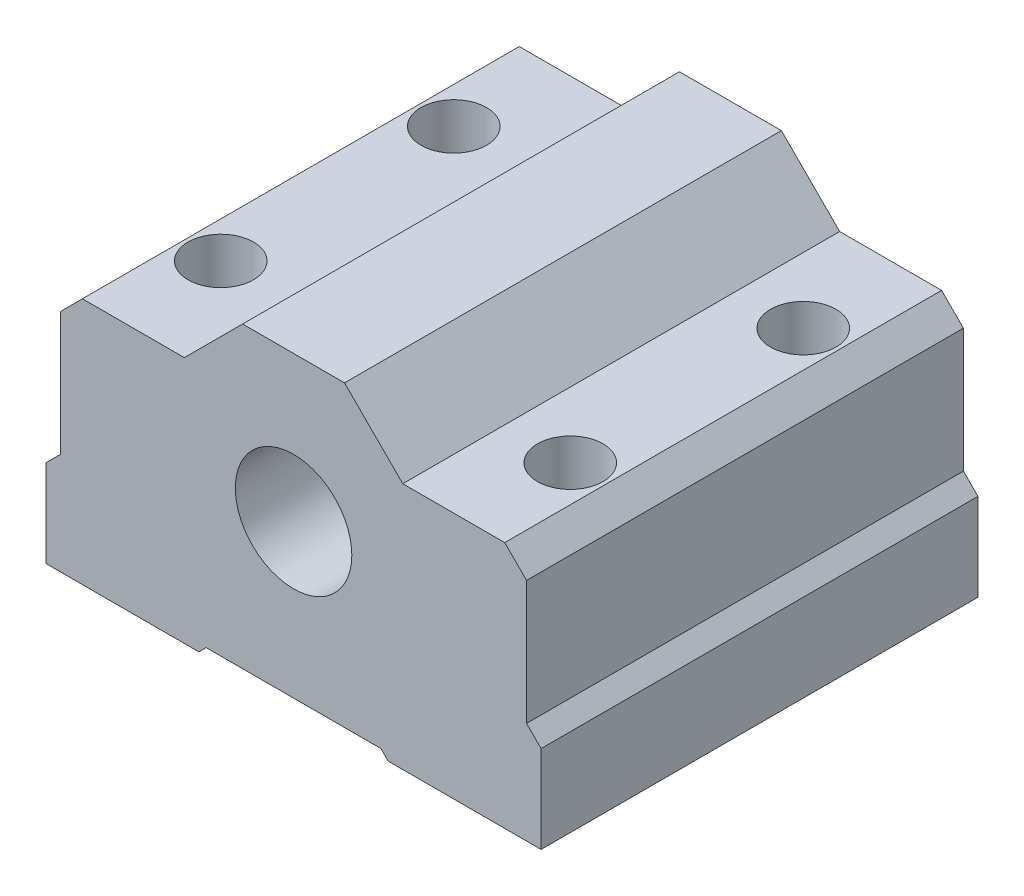
from build123d import *

# Parameters (mm, degrees)
BOSS_EXTRU_1_DEPTH      = 15
BOSS_EXTRU_1_DEPTH_BACK = 15
ESQUISSE1_R             = 4
D_GAGEMENT_M41_D        = 4.5


with BuildPart() as part:
    # Esquisse1 → Boss.-Extru.1 (new, two sides: drawn at the far end of the back side and taken through both)
    with BuildSketch(Plane.XY.offset(-BOSS_EXTRU_1_DEPTH_BACK)):
        Polygon((-17, -5), (-17, -11), (-6.5, -11), (-6, -10.5), (6, -10.5), (6.5, -11), (17, -11), (17, -5), (16, -4), (16, 4.5), (14.5, 6), (7.5, 6), (3.5, 10), (-3.5, 10), (-7.5, 6), (-14.5, 6), (-16, 4.5), (-16, -4), align=None)
        Circle(ESQUISSE1_R, mode=Mode.SUBTRACT)
    extrude(amount=BOSS_EXTRU_1_DEPTH + BOSS_EXTRU_1_DEPTH_BACK)

    # Dégagement M41 (through all)
    with Locations(Plane(origin=(0, 6, 0), x_dir=(1, 0, 0), z_dir=(0, 1, 0))):
        with Locations((-12, 8), (12, 8), (12, -8), (-12, -8)):
            Hole(D_GAGEMENT_M41_D / 2)


solid = part.part
